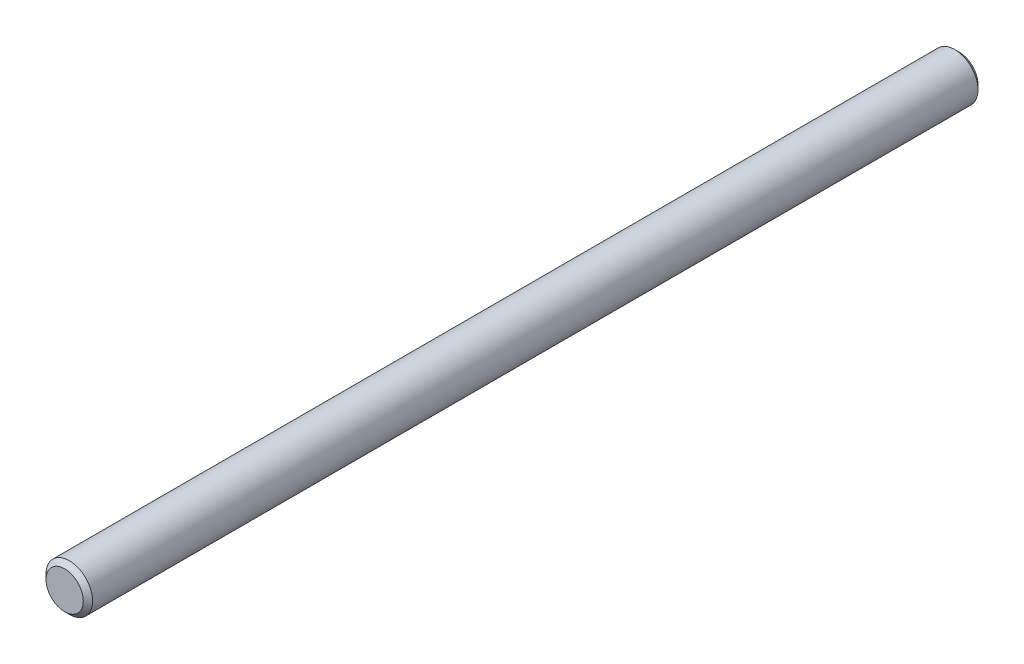
from build123d import *

# Parameters (mm, degrees)
SKETCH1_R      = 3.96875
EXTRUDE1_DEPTH = 76.2
CHAMFER1_SIZE  = 0.79375


with BuildPart() as part:
    # Sketch1 → Extrude1 (new body, symmetric)
    with BuildSketch(Plane.XY):
        Circle(SKETCH1_R)
    extrude(amount=EXTRUDE1_DEPTH, both=True)

    # Chamfer1
    chamfer1_edges = [part.edges().sort_by_distance(p)[0] for p in [
        (-3.96875, 0, -76.2),
        (-3.96875, 0, 76.2),
    ]]
    chamfer(chamfer1_edges, length=CHAMFER1_SIZE)


solid = part.part
